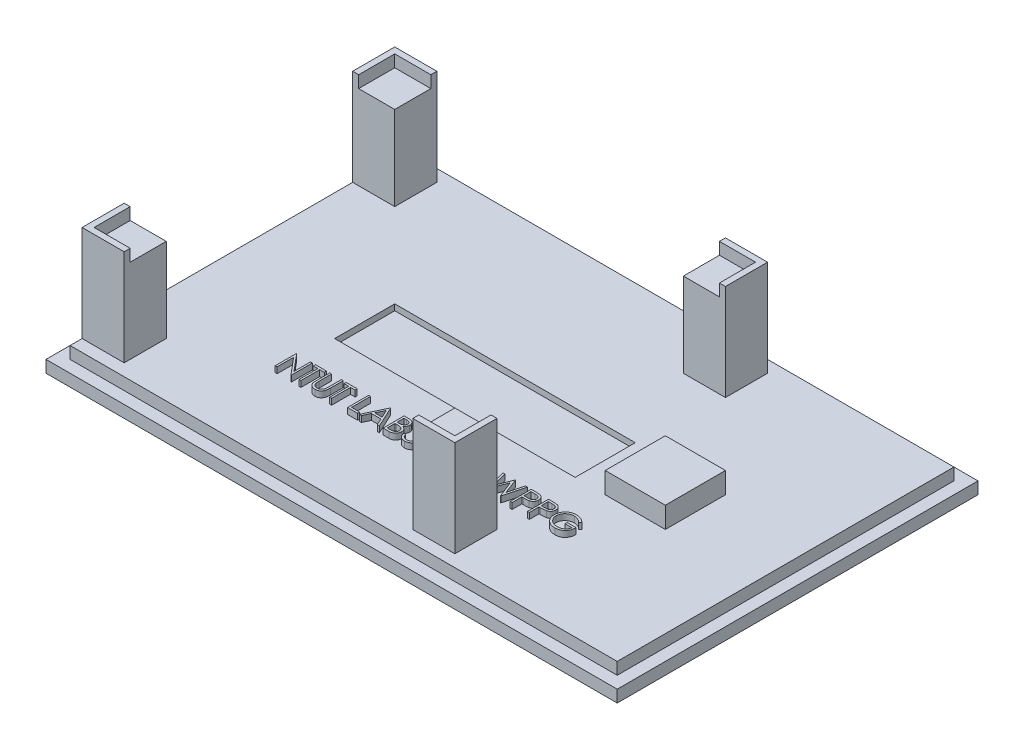
from build123d import *

# Parameters (mm, degrees)
SKETCH_1_W          = 95
SKETCH_1_H          = 60
EXTRUDE_1_DEPTH     = 2
SKETCH_2_W          = 91
SKETCH_2_H          = 56
EXTRUDE_2_DEPTH     = 2
SKETCH_5_W          = 10
SKETCH_5_H          = 10
EXTRUDE_6_DEPTH     = 3.5
SKETCH_15_W         = 7
SKETCH_15_H         = 7
EXTRUDE_7_DEPTH     = 16
SKETCH_27_W         = 6
SKETCH_27_H         = 6
CUT_EXTRUDE_1_DEPTH = 2
SKETCH_28_W         = 40
SKETCH_28_H         = 10
CUT_EXTRUDE_2_DEPTH = 1
EXTRUDE_8_DEPTH     = 1


with BuildPart() as part:
    # 草圖1 → 填料-伸長1 (new body)
    with BuildSketch(Plane(origin=(0, 0, 0), x_dir=(1, 0, 0), z_dir=(0, 1, 0))):
        with Locations((47.5, 30)):
            Rectangle(SKETCH_1_W, SKETCH_1_H)
    extrude(amount=EXTRUDE_1_DEPTH)

    # 草圖2 → 填料-伸長2 (add)
    with BuildSketch(Plane(origin=(0, 2, 0), x_dir=(1, 0, 0), z_dir=(0, 1, 0))):
        with Locations((47.5, 30)):
            Rectangle(SKETCH_2_W, SKETCH_2_H)
    extrude(amount=EXTRUDE_2_DEPTH)

    # 草圖5 → 填料-伸長6 (add)
    with BuildSketch(Plane(origin=(0, 4, 0), x_dir=(1, 0, 0), z_dir=(0, 1, 0))):
        with Locations((73, 30)):
            Rectangle(SKETCH_5_W, SKETCH_5_H)
    extrude(amount=EXTRUDE_6_DEPTH)

    # 草圖15 → 填料-伸長7 (add)
    with BuildSketch(Plane(origin=(0, 4, 0), x_dir=(1, 0, 0), z_dir=(0, 1, 0))):
        with Locations((5.5, 7.5)):
            Rectangle(SKETCH_15_W, SKETCH_15_H)
        with Locations((5.5, 52.5)):
            Rectangle(SKETCH_15_W, SKETCH_15_H)
        with Locations((60.5, 52.5)):
            Rectangle(SKETCH_15_W, SKETCH_15_H)
        with Locations((60.5, 7.5)):
            Rectangle(SKETCH_15_W, SKETCH_15_H)
    extrude(amount=EXTRUDE_7_DEPTH)

    # 草圖27 → 除料-伸長1 (cut)
    with BuildSketch(Plane(origin=(0, 20, 0), x_dir=(1, 0, 0), z_dir=(0, 1, 0))):
        with Locations((6, 52)):
            Rectangle(SKETCH_27_W, SKETCH_27_H)
        with Locations((60, 52)):
            Rectangle(SKETCH_27_W, SKETCH_27_H)
        with Locations((60, 8)):
            Rectangle(SKETCH_27_W, SKETCH_27_H)
        with Locations((6, 8)):
            Rectangle(SKETCH_27_W, SKETCH_27_H)
    extrude(amount=-CUT_EXTRUDE_1_DEPTH, mode=Mode.SUBTRACT)

    # 草圖28 → 除料-伸長2 (cut)
    with BuildSketch(Plane(origin=(0, 4, 0), x_dir=(1, 0, 0), z_dir=(0, 1, 0))):
        with Locations((43, 30)):
            Rectangle(SKETCH_28_W, SKETCH_28_H)
    extrude(amount=-CUT_EXTRUDE_2_DEPTH, mode=Mode.SUBTRACT)

    # 草圖29 → 填料-伸長8 (add)
    with BuildSketch(Plane(origin=(0, 4, 0), x_dir=(1, 0, 0), z_dir=(0, 1, 0))):
        Polygon((22.976581765, 15.14183964), (22.976581765, 18.64183964), (23.042487214, 18.64183964), (25.354786894, 15.887132108), (25.354786894, 18.64183964), (25.668889458, 18.64183964), (25.668889458, 15.14183964), (25.597375035, 15.14183964), (23.290684329, 17.890237076), (23.290684329, 15.14183964), align=None)
        Polygon((26.162479201, 18.282865281), (26.162479201, 18.64183964), (28.002222791, 18.64183964), (28.002222791, 18.282865281), (27.239402278, 18.282865281), (27.239402278, 15.14183964), (26.925299714, 15.14183964), (26.925299714, 18.282865281), align=None)
        with BuildLine():
            Line((28.540684329, 18.64183964), (28.854786894, 18.64183964))
            Line((28.854786894, 18.64183964), (28.854786894, 16.544784352))
            add(Edge.make_bspline(
                [(28.854786894, 16.544784352), (28.85474015, 16.515103616), (28.854651445, 16.458779305), (28.855243959, 16.378611005), (28.856903327, 16.307338546), (28.857949487, 16.244687198), (28.86027682, 16.190944451), (28.862174867, 16.14581914), (28.864615424, 16.109524937), (28.867548541, 16.088344011), (28.868809329, 16.07923948)],
                knots=[0, 0, 0, 0, 1.528628734, 2.90083645, 4.128790002, 5.200304208, 6.127813768, 6.898992206, 7.526736466, 8, 8, 8, 8], degree=3))
            add(Edge.make_bspline(
                [(28.868809329, 16.07923948), (28.873986788, 16.046392717), (28.884049975, 15.982549988), (28.909696352, 15.891641706), (28.945513853, 15.809710248), (28.987956896, 15.734198956), (29.043889507, 15.667209596), (29.110893043, 15.605497944), (29.192070811, 15.551526139), (29.282331417, 15.502175327), (29.379616654, 15.462510245), (29.479027921, 15.43251688), (29.5790709, 15.414237981), (29.646047065, 15.412121442), (29.679306124, 15.41107041)],
                knots=[0, 0, 0, 0, 1.035780045, 2.013197591, 2.933192213, 3.817615948, 4.702609284, 5.640816605, 6.646850145, 7.73207398, 8.84249596, 9.914020372, 10.964143139, 12, 12, 12, 12], degree=3))
            add(Edge.make_bspline(
                [(29.679306124, 15.41107041), (29.707859865, 15.41214426), (29.764802427, 15.414285758), (29.849408857, 15.427547189), (29.931808966, 15.451447755), (30.012409646, 15.482287513), (30.08796063, 15.523035104), (30.158504072, 15.570105944), (30.221468007, 15.62531682), (30.278926004, 15.686417164), (30.32896094, 15.755356964), (30.372332082, 15.830635102), (30.407858011, 15.913384449), (30.425401536, 15.971538872), (30.434414297, 16.001414961)],
                knots=[0, 0, 0, 0, 0.994687771, 1.983630487, 2.973142513, 3.978332533, 4.983357753, 5.956394766, 6.925816176, 7.893390482, 8.871859704, 9.88551698, 10.913711441, 12, 12, 12, 12], degree=3))
            add(Edge.make_bspline(
                [(30.434414297, 16.001414961), (30.437414423, 16.013763535), (30.444099911, 16.041281135), (30.450346956, 16.087802426), (30.456853481, 16.14269179), (30.461368051, 16.206343603), (30.465769272, 16.278544575), (30.468402345, 16.359670833), (30.469619377, 16.449427794), (30.469982058, 16.512064955), (30.470171509, 16.544784352)],
                knots=[0, 0, 0, 0, 0.558680831, 1.244966039, 2.062412453, 2.990489873, 4.051219941, 5.244515665, 6.560634259, 8, 8, 8, 8], degree=3))
            Line((30.470171509, 16.544784352), (30.470171509, 18.64183964))
            Line((30.470171509, 18.64183964), (30.784274073, 18.64183964))
            Line((30.784274073, 18.64183964), (30.784274073, 16.527957429))
            add(Edge.make_bspline(
                [(30.784274073, 16.527957429), (30.784019953, 16.48985905), (30.783524021, 16.415507747), (30.779223445, 16.306556388), (30.772366445, 16.203203407), (30.762678357, 16.10543491), (30.749841354, 16.013600751), (30.735566133, 15.926895983), (30.7173866, 15.84594299), (30.696153199, 15.770110572), (30.671879651, 15.697925059), (30.640438503, 15.629416444), (30.605014003, 15.562502045), (30.56299935, 15.498193936), (30.515787967, 15.436207383), (30.462336286, 15.376918308), (30.404412126, 15.319379261), (30.341052566, 15.265066195), (30.273302041, 15.215257518), (30.201362083, 15.171459747), (30.125785313, 15.13443613), (30.046768187, 15.103960205), (29.964276984, 15.081045606), (29.878309625, 15.06397045), (29.788670431, 15.054268153), (29.727705775, 15.052826223), (29.696834169, 15.052096051)],
                knots=[0, 0, 0, 0, 1.316592851, 2.569410997, 3.76748051, 4.895814652, 5.963796859, 6.97159953, 7.931736103, 8.829262218, 9.692595152, 10.560224239, 11.431080259, 12.30701507, 13.211635791, 14.121146779, 15.063487852, 16.031507147, 17.00238618, 17.966455255, 18.938106653, 19.907068911, 20.888905087, 21.893141452, 22.933117798, 24, 24, 24, 24], degree=3))
            add(Edge.make_bspline(
                [(29.696834169, 15.052096051), (29.663165067, 15.052880816), (29.597106408, 15.054420523), (29.49976834, 15.063243273), (29.406454144, 15.079861667), (29.316178267, 15.101021611), (29.23016977, 15.130205348), (29.147276326, 15.164303473), (29.068917644, 15.206180733), (28.993822516, 15.252774126), (28.92399776, 15.305198764), (28.859900357, 15.362338938), (28.801424486, 15.423279316), (28.74955579, 15.488679681), (28.703434905, 15.558031388), (28.663704692, 15.631530628), (28.629591448, 15.709148944), (28.611984881, 15.763102145), (28.603084169, 15.790377301)],
                knots=[0, 0, 0, 0, 1.13879206, 2.234305948, 3.301075583, 4.341971843, 5.366689343, 6.369221514, 7.369726634, 8.367512178, 9.355451585, 10.318319045, 11.268648973, 12.207971039, 13.137398894, 14.081662264, 15.030215811, 16, 16, 16, 16], degree=3))
            add(Edge.make_bspline(
                [(28.603084169, 15.790377301), (28.597907011, 15.809009875), (28.58667764, 15.849424344), (28.574652342, 15.916310833), (28.56454326, 15.99332575), (28.555037702, 16.080474369), (28.549428744, 16.177824235), (28.544511306, 16.285333151), (28.540649687, 16.403131113), (28.540672459, 16.485185628), (28.540684329, 16.527957429)],
                knots=[0, 0, 0, 0, 0.625038921, 1.35572334, 2.194682327, 3.136881307, 4.189498639, 5.346923369, 6.617055217, 8, 8, 8, 8], degree=3))
            Line((28.540684329, 16.527957429), (28.540684329, 18.64183964))
        make_face()
        Polygon((31.277863817, 18.282865281), (31.277863817, 18.64183964), (33.117607406, 18.64183964), (33.117607406, 18.282865281), (32.354786894, 18.282865281), (32.354786894, 15.14183964), (32.040684329, 15.14183964), (32.040684329, 18.282865281), align=None)
        Polygon((35.002222791, 18.64183964), (35.316325355, 18.64183964), (35.316325355, 15.500813999), (36.662479201, 15.500813999), (36.662479201, 15.14183964), (35.002222791, 15.14183964), align=None)
        Polygon((38.681709971, 18.64183964), (40.297094586, 15.14183964), (39.955648272, 15.14183964), (39.438220387, 16.263634512), (37.851581765, 16.263634512), (37.319430323, 15.14183964), (36.976581765, 15.14183964), (38.636838176, 18.64183964), align=None)
        Polygon((38.655768464, 17.959648134), (38.021954362, 16.622608871), (39.272755644, 16.622608871), align=None, mode=Mode.SUBTRACT)
        with BuildLine():
            Line((40.925299714, 18.64183964), (41.608192342, 18.64183964))
            add(Edge.make_bspline(
                [(41.608192342, 18.64183964), (41.64162082, 18.64166389), (41.706413531, 18.641323242), (41.800632973, 18.636040111), (41.888881783, 18.628836441), (41.971185556, 18.617406348), (42.047506258, 18.603614571), (42.118073895, 18.586912755), (42.182664068, 18.566886141), (42.259776804, 18.53503986), (42.347697465, 18.487716692), (42.442895858, 18.417788127), (42.524300097, 18.332255664), (42.594486414, 18.235773008), (42.650287534, 18.129637236), (42.690656831, 18.016378048), (42.716214706, 17.897456306), (42.718843141, 17.815813128), (42.720171509, 17.77455198)],
                knots=[0, 0, 0, 0, 1.001505555, 1.941167018, 2.826882275, 3.653841531, 4.429895133, 5.150066043, 5.825578002, 6.45369114, 7.647487171, 8.808567382, 9.977351308, 11.170798116, 12.373658725, 13.556498008, 14.765093433, 16, 16, 16, 16], degree=3))
            add(Edge.make_bspline(
                [(42.720171509, 17.77455198), (42.719078291, 17.735899424), (42.716930013, 17.659943507), (42.696387254, 17.548849398), (42.664226585, 17.443098179), (42.619521336, 17.343075794), (42.56141934, 17.251042181), (42.492561021, 17.166254915), (42.409484219, 17.092303858), (42.347240979, 17.050960955), (42.315624233, 17.029960634)],
                knots=[0, 0, 0, 0, 1.044552857, 2.05264487, 3.044412934, 4.028983338, 5.005914585, 5.980388656, 6.974128949, 8, 8, 8, 8], degree=3))
            add(Edge.make_bspline(
                [(42.315624233, 17.029960634), (42.355384661, 17.014695635), (42.431456208, 16.985489911), (42.536142221, 16.933854447), (42.626337066, 16.877692336), (42.702734212, 16.816360486), (42.768071867, 16.750251675), (42.825124808, 16.678396561), (42.873806182, 16.599857803), (42.915519106, 16.515454268), (42.948067862, 16.426047799), (42.972443766, 16.332477023), (42.986411215, 16.235077468), (42.988398857, 16.168792089), (42.989402278, 16.135329224)],
                knots=[0, 0, 0, 0, 1.27268992, 2.434971085, 3.483601985, 4.442670788, 5.356604649, 6.2567628, 7.179492994, 8.113709626, 9.066344395, 10.018646069, 10.999752585, 12, 12, 12, 12], degree=3))
            add(Edge.make_bspline(
                [(42.989402278, 16.135329224), (42.988425432, 16.101162352), (42.98650346, 16.033938073), (42.972323488, 15.935182939), (42.948314381, 15.840807992), (42.915243235, 15.75020281), (42.872080921, 15.663542675), (42.819552956, 15.580729411), (42.756921393, 15.502595081), (42.686858524, 15.428271457), (42.607596378, 15.36144367), (42.522080623, 15.301927963), (42.429234303, 15.252981901), (42.330582309, 15.21186588), (42.225017993, 15.180458681), (42.113015386, 15.158486107), (41.994671084, 15.14368107), (41.913461333, 15.142463866), (41.871814137, 15.14183964)],
                knots=[0, 0, 0, 0, 0.978564426, 1.925352924, 2.850884081, 3.763762016, 4.682927383, 5.618979971, 6.567305752, 7.547517671, 8.540179244, 9.531824382, 10.526200242, 11.540722885, 12.589160233, 13.674978461, 14.80764778, 16, 16, 16, 16], degree=3))
            Line((41.871814137, 15.14183964), (40.925299714, 15.14183964))
            Line((40.925299714, 15.14183964), (40.925299714, 18.64183964))
        make_face()
        with BuildLine():
            Line((41.239402278, 18.282865281), (41.239402278, 17.16107041))
            Line((41.239402278, 17.16107041), (41.450439938, 17.16107041))
            add(Edge.make_bspline(
                [(41.450439938, 17.16107041), (41.481288734, 17.161470333), (41.540894893, 17.162243065), (41.62721479, 17.164456582), (41.707339808, 17.170654626), (41.781131641, 17.176850888), (41.848474085, 17.186925476), (41.909217946, 17.198917598), (41.964316543, 17.211600504), (42.027856089, 17.23316999), (42.099929037, 17.265047666), (42.176762141, 17.314519502), (42.244496611, 17.373443855), (42.301693799, 17.441434817), (42.348505269, 17.516301003), (42.381018984, 17.596847883), (42.403066269, 17.681068015), (42.4050578, 17.738886268), (42.406068945, 17.768241884)],
                knots=[0, 0, 0, 0, 1.156816544, 2.235205308, 3.236616184, 4.169592532, 5.011045266, 5.787822928, 6.49130361, 7.128639758, 8.301311294, 9.436451833, 10.541879658, 11.654887649, 12.756523258, 13.837046038, 14.901820046, 16, 16, 16, 16], degree=3))
            add(Edge.make_bspline(
                [(42.406068945, 17.768241884), (42.405542765, 17.787667655), (42.404510605, 17.825773428), (42.396057302, 17.881322782), (42.381689728, 17.933566534), (42.363235435, 17.983220645), (42.337446746, 18.028732495), (42.307083282, 18.071675691), (42.270397592, 18.110587809), (42.22864028, 18.146957307), (42.180631657, 18.179201835), (42.126400365, 18.207442598), (42.065212688, 18.230183375), (41.998099833, 18.250099527), (41.924028745, 18.264087821), (41.843854192, 18.275741209), (41.756919473, 18.281673951), (41.69677437, 18.282459314), (41.665684329, 18.282865281)],
                knots=[0, 0, 0, 0, 0.91205012, 1.789085906, 2.630437955, 3.453916878, 4.269457761, 5.079663411, 5.91843418, 6.774407191, 7.675494373, 8.627863946, 9.638891023, 10.736472738, 11.911756761, 13.175263542, 14.539845004, 16, 16, 16, 16], degree=3))
            Line((41.665684329, 18.282865281), (41.239402278, 18.282865281))
        make_face(mode=Mode.SUBTRACT)
        with BuildLine():
            Line((41.239402278, 16.802096051), (41.239402278, 15.500813999))
            Line((41.239402278, 15.500813999), (41.686717983, 15.500813999))
            add(Edge.make_bspline(
                [(41.686717983, 15.500813999), (41.718736909, 15.501197747), (41.780449168, 15.501937369), (41.869550398, 15.504351924), (41.952133502, 15.5098442), (42.027821637, 15.518490049), (42.09743209, 15.527868498), (42.160129793, 15.540479779), (42.216422987, 15.55492874), (42.281697294, 15.577262912), (42.355200803, 15.611959383), (42.434411659, 15.664273609), (42.504837877, 15.726596917), (42.564643136, 15.798727831), (42.613656125, 15.877159158), (42.64931158, 15.960304508), (42.671302437, 16.046790036), (42.673964606, 16.105756748), (42.675299714, 16.135329224)],
                knots=[0, 0, 0, 0, 1.160039823, 2.235823828, 3.228722157, 4.157150951, 4.99529583, 5.772374946, 6.472645482, 7.099169577, 8.269452708, 9.405989375, 10.527446681, 11.663510218, 12.788923519, 13.866172445, 14.929861265, 16, 16, 16, 16], degree=3))
            add(Edge.make_bspline(
                [(42.675299714, 16.135329224), (42.67502361, 16.153822564), (42.674475855, 16.190510946), (42.66621524, 16.244426765), (42.65420137, 16.296652639), (42.638669936, 16.347330379), (42.616050469, 16.395543755), (42.589643924, 16.442246315), (42.558682522, 16.487499794), (42.510438356, 16.544712048), (42.440266372, 16.610629061), (42.340559596, 16.675166563), (42.227187299, 16.72721437), (42.144959806, 16.749313846), (42.102483208, 16.760729865)],
                knots=[0, 0, 0, 0, 0.723448775, 1.435228256, 2.130040452, 2.821711965, 3.505591119, 4.210454504, 4.921174351, 5.648778258, 7.137944449, 8.670945889, 10.280296675, 12, 12, 12, 12], degree=3))
            add(Edge.make_bspline(
                [(42.102483208, 16.760729865), (42.085454112, 16.764184949), (42.048531519, 16.771676283), (41.988323939, 16.779583987), (41.91958807, 16.786629047), (41.842165193, 16.791840204), (41.755957352, 16.797226748), (41.660780433, 16.799321569), (41.557023118, 16.801820829), (41.485030746, 16.802001963), (41.447635451, 16.802096051)],
                knots=[0, 0, 0, 0, 0.634451884, 1.375622551, 2.216452059, 3.157844607, 4.20941857, 5.370758133, 6.634282058, 8, 8, 8, 8], degree=3))
            Line((41.447635451, 16.802096051), (41.239402278, 16.802096051))
        make_face(mode=Mode.SUBTRACT)
        with BuildLine():
            Line((43.841966381, 17.834147333), (43.527863817, 17.834147333))
            add(Edge.make_bspline(
                [(43.527863817, 17.834147333), (43.536373367, 17.869379817), (43.553008843, 17.938256441), (43.587706416, 18.036663702), (43.625505672, 18.129787223), (43.670894776, 18.215883297), (43.72040353, 18.2966822), (43.777126252, 18.370351324), (43.838445974, 18.43876429), (43.906270924, 18.499477527), (43.977399585, 18.554455256), (44.052834205, 18.601330314), (44.131057099, 18.641654467), (44.212610232, 18.674874699), (44.297736403, 18.699900222), (44.385666027, 18.718057028), (44.476629527, 18.729848142), (44.538377117, 18.730998905), (44.569730804, 18.73158323)],
                knots=[0, 0, 0, 0, 1.162005537, 2.271625781, 3.343758855, 4.383309926, 5.390229558, 6.379919256, 7.361854164, 8.333198761, 9.295911338, 10.242430842, 11.177959212, 12.116337295, 13.062827104, 14.020064771, 14.994644689, 16, 16, 16, 16], degree=3))
            add(Edge.make_bspline(
                [(44.569730804, 18.73158323), (44.615413546, 18.730204), (44.705782557, 18.727475624), (44.838545604, 18.702561188), (44.966572423, 18.663136056), (45.088461671, 18.608662328), (45.201680103, 18.541475015), (45.30241629, 18.461510278), (45.389304801, 18.370310977), (45.462199179, 18.269578413), (45.519274178, 18.161922903), (45.561360551, 18.051122746), (45.586982232, 17.937440775), (45.590302789, 17.860683495), (45.591966381, 17.822228262)],
                knots=[0, 0, 0, 0, 1.083050992, 2.142477498, 3.193116406, 4.255571735, 5.30263384, 6.308962982, 7.297363603, 8.282367274, 9.249857812, 10.179914175, 11.08814088, 12, 12, 12, 12], degree=3))
            add(Edge.make_bspline(
                [(45.591966381, 17.822228262), (45.59080279, 17.785221467), (45.588525823, 17.712804913), (45.569192117, 17.607083416), (45.536655854, 17.507441816), (45.491586092, 17.413460653), (45.433244541, 17.325735814), (45.362571844, 17.244069923), (45.279069183, 17.168100765), (45.215790245, 17.124581292), (45.183212374, 17.102176179)],
                knots=[0, 0, 0, 0, 1.024540389, 2.004866551, 2.965041327, 3.920577974, 4.882998113, 5.874504559, 6.905732034, 8, 8, 8, 8], degree=3))
            add(Edge.make_bspline(
                [(45.183212374, 17.102176179), (45.220444129, 17.084198007), (45.294211003, 17.04857805), (45.394761533, 16.978722292), (45.486039408, 16.898065945), (45.536943127, 16.835123292), (45.562519265, 16.803498294)],
                knots=[0, 0, 0, 0, 1.015518401, 2.012035669, 3.001164323, 4, 4, 4, 4], degree=3))
            add(Edge.make_bspline(
                [(45.562519265, 16.803498294), (45.579360608, 16.780440543), (45.612767504, 16.734702626), (45.654003038, 16.6611662), (45.691412152, 16.586814711), (45.720562371, 16.509655305), (45.743136238, 16.430582291), (45.75927227, 16.349459895), (45.769296411, 16.266221873), (45.770731963, 16.209909392), (45.77145356, 16.181603262)],
                knots=[0, 0, 0, 0, 1.025084078, 2.033381695, 3.024893161, 4.013698104, 4.991890475, 5.976764909, 6.982997093, 8, 8, 8, 8], degree=3))
            add(Edge.make_bspline(
                [(45.77145356, 16.181603262), (45.769659047, 16.132593541), (45.766078465, 16.034804739), (45.73407439, 15.890330018), (45.68446115, 15.749104515), (45.614004214, 15.614029676), (45.528136705, 15.487649295), (45.425979381, 15.374572986), (45.308692972, 15.277374382), (45.177887323, 15.196164154), (45.036170195, 15.131246231), (44.884594603, 15.086188789), (44.725344549, 15.056842789), (44.616137251, 15.05369592), (44.560616221, 15.052096051)],
                knots=[0, 0, 0, 0, 0.955779014, 1.907060117, 2.875433937, 3.871313158, 4.872415639, 5.851225146, 6.836215519, 7.83643374, 8.849228613, 9.86973379, 10.916971861, 12, 12, 12, 12], degree=3))
            add(Edge.make_bspline(
                [(44.560616221, 15.052096051), (44.52319692, 15.052964264), (44.449568215, 15.054672618), (44.341324717, 15.066351219), (44.238003017, 15.087681225), (44.13946342, 15.11638453), (44.045618383, 15.152776272), (43.956754278, 15.19809497), (43.872324384, 15.251406472), (43.793125433, 15.31334006), (43.719166866, 15.3826214), (43.652414141, 15.46048041), (43.591754348, 15.545477813), (43.53881171, 15.63860087), (43.491174757, 15.738646127), (43.4519938, 15.846894625), (43.417508232, 15.962378647), (43.401474768, 16.042856388), (43.393248432, 16.084147333)],
                knots=[0, 0, 0, 0, 1.048658725, 2.063410685, 3.046034179, 4.001477787, 4.936774919, 5.862367409, 6.792675028, 7.730719943, 8.675894397, 9.627829632, 10.600096036, 11.597688215, 12.626045268, 13.701542398, 14.82072376, 16, 16, 16, 16], degree=3))
            Line((43.393248432, 16.084147333), (43.707350996, 16.084147333))
            add(Edge.make_bspline(
                [(43.707350996, 16.084147333), (43.715534288, 16.057198319), (43.7314515, 16.004780148), (43.758545798, 15.929339842), (43.78941407, 15.860181789), (43.822528629, 15.796798667), (43.857307075, 15.738566264), (43.896222, 15.687024395), (43.936391145, 15.639909193), (43.966670499, 15.613364581), (43.981489618, 15.600373294)],
                knots=[0, 0, 0, 0, 1.198163088, 2.33053128, 3.407730985, 4.417276592, 5.372219308, 6.28897303, 7.162600585, 8, 8, 8, 8], degree=3))
            add(Edge.make_bspline(
                [(43.981489618, 15.600373294), (44.001086194, 15.58526496), (44.040218857, 15.555094929), (44.103987088, 15.5165933), (44.171051975, 15.483232275), (44.242866649, 15.457748579), (44.317881419, 15.436170918), (44.397308784, 15.422050399), (44.480448002, 15.412362228), (44.537215765, 15.411507296), (44.566225195, 15.41107041)],
                knots=[0, 0, 0, 0, 0.946170439, 1.889420265, 2.845303464, 3.807233317, 4.801018734, 5.828864929, 6.890507805, 8, 8, 8, 8], degree=3))
            add(Edge.make_bspline(
                [(44.566225195, 15.41107041), (44.598978698, 15.411686315), (44.663025344, 15.412890664), (44.756480204, 15.423966371), (44.845387651, 15.440096785), (44.928760577, 15.465009768), (45.007691084, 15.495790619), (45.081072734, 15.534439024), (45.14986884, 15.579783746), (45.213198246, 15.631322905), (45.270143753, 15.6877444), (45.320283266, 15.746757471), (45.362907928, 15.8081133), (45.397291506, 15.872151421), (45.424442056, 15.93860665), (45.442925257, 16.00766548), (45.455776772, 16.078762746), (45.456823384, 16.127091715), (45.457350996, 16.151455025)],
                knots=[0, 0, 0, 0, 1.217147791, 2.380027433, 3.494444702, 4.572153297, 5.609568379, 6.639424714, 7.649109417, 8.668170816, 9.669597737, 10.625200337, 11.543417969, 12.441394052, 13.322311151, 14.205496177, 15.095365482, 16, 16, 16, 16], degree=3))
            add(Edge.make_bspline(
                [(45.457350996, 16.151455025), (45.455820695, 16.184066364), (45.452767706, 16.249126772), (45.429459127, 16.344844346), (45.391120262, 16.437067759), (45.337447751, 16.524223549), (45.272112023, 16.60499945), (45.195747116, 16.677070933), (45.107718887, 16.736541024), (45.026699018, 16.77762968), (44.954933862, 16.805666756), (44.893518477, 16.82434172), (44.824761874, 16.840155376), (44.749495525, 16.854867647), (44.667152309, 16.867388995), (44.577821871, 16.877830811), (44.481486109, 16.886185852), (44.414794943, 16.889916947), (44.380427919, 16.89183964)],
                knots=[0, 0, 0, 0, 1.07054697, 2.135767047, 3.216561865, 4.33974944, 5.486079747, 6.621378074, 7.775625952, 8.963672916, 9.598146892, 10.304877434, 11.070270905, 11.915000392, 12.823868403, 13.805723172, 14.86925407, 16, 16, 16, 16], degree=3))
            Line((44.380427919, 16.89183964), (44.380427919, 17.250813999))
            add(Edge.make_bspline(
                [(44.380427919, 17.250813999), (44.423729085, 17.251548803), (44.508545432, 17.252988103), (44.632439736, 17.270396113), (44.750913048, 17.294476742), (44.86133979, 17.331361934), (44.961988504, 17.374202231), (45.049308106, 17.42405444), (45.122075253, 17.479469189), (45.179936325, 17.541301799), (45.223465553, 17.607616846), (45.255292351, 17.676733504), (45.274092677, 17.749257565), (45.276602344, 17.798752233), (45.277863817, 17.823630506)],
                knots=[0, 0, 0, 0, 1.321986639, 2.589447074, 3.816329219, 5.01088745, 6.139805852, 7.153945165, 8.075214402, 8.924034688, 9.728124013, 10.488707548, 11.240355623, 12, 12, 12, 12], degree=3))
            add(Edge.make_bspline(
                [(45.277863817, 17.823630506), (45.277449406, 17.841908251), (45.276624955, 17.878270958), (45.266227677, 17.931396027), (45.250603636, 17.982896973), (45.229123907, 18.032554783), (45.200373708, 18.080025057), (45.165967721, 18.125712506), (45.124999621, 18.169356285), (45.078054174, 18.210036604), (45.027642369, 18.248805841), (44.972392594, 18.281719478), (44.913970719, 18.309864541), (44.852312065, 18.333074043), (44.787216534, 18.350533331), (44.718989977, 18.363069172), (44.647502293, 18.370906827), (44.598730561, 18.372035243), (44.573937535, 18.372608871)],
                knots=[0, 0, 0, 0, 0.884392785, 1.759457502, 2.611959086, 3.489218968, 4.37281399, 5.2945488, 6.255912374, 7.266815255, 8.301784654, 9.332968512, 10.37626691, 11.440494194, 12.520033166, 13.637162961, 14.798855837, 16, 16, 16, 16], degree=3))
            add(Edge.make_bspline(
                [(44.573937535, 18.372608871), (44.534085867, 18.371217509), (44.45624629, 18.368499856), (44.344031373, 18.344696842), (44.239712039, 18.306718759), (44.159973373, 18.261385739), (44.101090799, 18.216635305), (44.05901386, 18.177552919), (44.01769335, 18.134120095), (43.979847673, 18.08366172), (43.941573696, 18.02959493), (43.906729135, 17.969171248), (43.872869443, 17.903966854), (43.852466893, 17.857871219), (43.841966381, 17.834147333)],
                knots=[0, 0, 0, 0, 1.472543308, 2.876219568, 4.221790263, 5.565193594, 6.249813518, 6.953379497, 7.687249741, 8.463570142, 9.283606569, 10.136032583, 11.040678096, 12, 12, 12, 12], degree=3))
        make_face()
        with BuildLine():
            Line((46.534274073, 17.564916563), (46.220171509, 17.564916563))
            add(Edge.make_bspline(
                [(46.220171509, 17.564916563), (46.222218662, 17.606587451), (46.226239216, 17.688427966), (46.245067505, 17.807751872), (46.272008382, 17.921806671), (46.310099836, 18.029676585), (46.357406114, 18.132315392), (46.414136142, 18.229315408), (46.481329992, 18.320306597), (46.557536726, 18.40444544), (46.640305365, 18.481633011), (46.729611305, 18.548288253), (46.823456332, 18.604605925), (46.921555731, 18.651687167), (47.025016295, 18.687027013), (47.132899152, 18.713248652), (47.245678289, 18.729024998), (47.322518311, 18.730720783), (47.361597791, 18.73158323)],
                knots=[0, 0, 0, 0, 1.10065271, 2.161652631, 3.183658789, 4.190468796, 5.17591951, 6.163126047, 7.15150782, 8.156236427, 9.156009102, 10.134482811, 11.092018607, 12.041330605, 13.001268258, 13.972401359, 14.968799086, 16, 16, 16, 16], degree=3))
            add(Edge.make_bspline(
                [(47.361597791, 18.73158323), (47.399975865, 18.730684774), (47.47538741, 18.728919339), (47.585449424, 18.71375831), (47.690226719, 18.690012718), (47.789514485, 18.656697302), (47.88252055, 18.611912874), (47.969943594, 18.558115336), (48.052824405, 18.495895504), (48.127431189, 18.422641691), (48.195939268, 18.344439306), (48.255041523, 18.260951403), (48.305654687, 18.174722117), (48.347842366, 18.085093915), (48.378898505, 17.991222887), (48.402476713, 17.894475684), (48.415804127, 17.793850873), (48.417849551, 17.725744318), (48.418889458, 17.691118487)],
                knots=[0, 0, 0, 0, 1.111607364, 2.184268762, 3.212621178, 4.221274766, 5.211760367, 6.196651075, 7.1921475, 8.207485113, 9.220403448, 10.201281604, 11.166441695, 12.114753415, 13.065576456, 14.026450734, 14.996634279, 16, 16, 16, 16], degree=3))
            add(Edge.make_bspline(
                [(48.418889458, 17.691118487), (48.417196195, 17.642370652), (48.413839383, 17.545730438), (48.385125007, 17.403715576), (48.340278496, 17.266122156), (48.286281139, 17.155384854), (48.231808695, 17.066151361), (48.182721187, 16.992682656), (48.125256376, 16.913577187), (48.058577878, 16.82909985), (47.984065006, 16.738588945), (47.901042843, 16.642099149), (47.808919361, 16.54062738), (47.74426086, 16.471321778), (47.710756445, 16.435409352)],
                knots=[0, 0, 0, 0, 1.184426356, 2.348067706, 3.509069118, 4.696110526, 5.333549288, 6.050745305, 6.844228056, 7.710549037, 8.667450064, 9.695053472, 10.805634456, 12, 12, 12, 12], degree=3))
            Line((47.710756445, 16.435409352), (46.835055323, 15.500813999))
            Line((46.835055323, 15.500813999), (48.463761253, 15.500813999))
            Line((48.463761253, 15.500813999), (48.463761253, 15.14183964))
            Line((48.463761253, 15.14183964), (46.085556124, 15.14183964))
            Line((46.085556124, 15.14183964), (47.442927919, 16.590357269))
            add(Edge.make_bspline(
                [(47.442927919, 16.590357269), (47.475975806, 16.624855575), (47.539454033, 16.691119762), (47.62923661, 16.787862722), (47.709875598, 16.877612263), (47.781892991, 16.960198811), (47.843726496, 17.036830379), (47.898598728, 17.105025082), (47.942564319, 17.167779533), (47.990279715, 17.240520147), (48.036493696, 17.329332464), (48.076206052, 17.437866153), (48.100420901, 17.549593406), (48.103325736, 17.625095443), (48.104786894, 17.663073615)],
                knots=[0, 0, 0, 0, 1.329631726, 2.553950428, 3.673215718, 4.687767853, 5.603093632, 6.413772471, 7.123043292, 7.734684054, 8.834405432, 9.900288307, 10.943827018, 12, 12, 12, 12], degree=3))
            add(Edge.make_bspline(
                [(48.104786894, 17.663073615), (48.104151151, 17.686955013), (48.102898225, 17.734020664), (48.091840528, 17.803026423), (48.075130022, 17.869591236), (48.051184764, 17.933919855), (48.019578024, 17.995365508), (47.981104644, 18.054002988), (47.93671458, 18.110691953), (47.885363311, 18.163845251), (47.828951791, 18.212526456), (47.769357542, 18.255650542), (47.706307437, 18.291689653), (47.640067315, 18.32123315), (47.570821846, 18.344408531), (47.498437101, 18.36046711), (47.423113084, 18.370549594), (47.371679589, 18.371913766), (47.34547199, 18.372608871)],
                knots=[0, 0, 0, 0, 0.991446411, 1.95395049, 2.89581595, 3.838931463, 4.798493298, 5.75982156, 6.748411868, 7.785213223, 8.824556874, 9.840280684, 10.836137867, 11.835679398, 12.848801643, 13.863922112, 14.911575587, 16, 16, 16, 16], degree=3))
            add(Edge.make_bspline(
                [(47.34547199, 18.372608871), (47.318101157, 18.371893839), (47.264349361, 18.370489634), (47.185430328, 18.36066697), (47.11014455, 18.343721129), (47.038302647, 18.320544455), (46.969783062, 18.291085906), (46.904919017, 18.254394161), (46.843856128, 18.210610668), (46.786479605, 18.160970112), (46.733615626, 18.105702511), (46.68716875, 18.044092548), (46.646584736, 17.977265132), (46.611175502, 17.905400582), (46.582419812, 17.827846802), (46.560446662, 17.744879097), (46.543059815, 17.656857715), (46.537251294, 17.59607263), (46.534274073, 17.564916563)],
                knots=[0, 0, 0, 0, 1.031018746, 2.02475058, 2.990194455, 3.934040569, 4.864654155, 5.795059489, 6.735614925, 7.690564532, 8.649604399, 9.611025574, 10.590972636, 11.591080095, 12.624614302, 13.701020113, 14.821632451, 16, 16, 16, 16], degree=3))
        make_face()
        Polygon((49.521754041, 18.64183964), (50.168889458, 18.64183964), (50.168889458, 15.14183964), (49.854786894, 15.14183964), (49.854786894, 18.282865281), (49.316325355, 18.282865281), align=None)
        Polygon((52.95094074, 15.14183964), (53.412980003, 18.64183964), (53.457851797, 18.64183964), (54.902863817, 15.770044769), (56.344370227, 18.64183964), (56.389943144, 18.64183964), (56.854786894, 15.14183964), (56.539282086, 15.14183964), (56.204145868, 17.660269128), (54.940724394, 15.14183964), (54.869911092, 15.14183964), (53.601581765, 17.665878102), (53.267146669, 15.14183964), align=None)
        Polygon((57.348376637, 18.64183964), (57.672996028, 18.64183964), (58.357992022, 16.075032749), (59.37672199, 18.64183964), (59.422294906, 18.64183964), (60.422094586, 16.092560794), (61.110596188, 18.64183964), (61.431709971, 18.64183964), (60.488000035, 15.14183964), (60.44312824, 15.14183964), (59.390043304, 17.818722653), (58.324338176, 15.14183964), (58.279466381, 15.14183964), align=None)
        with BuildLine():
            Line((62.059915099, 18.64183964), (62.746313336, 18.64183964))
            add(Edge.make_bspline(
                [(62.746313336, 18.64183964), (62.793524242, 18.641787744), (62.883982435, 18.641688309), (63.013697491, 18.638673563), (63.131507222, 18.634646871), (63.237157603, 18.629064978), (63.330973701, 18.622468387), (63.412531001, 18.613216348), (63.482470557, 18.603556052), (63.524377007, 18.593734646), (63.543488817, 18.589255506)],
                knots=[0, 0, 0, 0, 1.415646017, 2.712440637, 3.8905458, 4.950247383, 5.884950622, 6.709939814, 7.411656543, 8, 8, 8, 8], degree=3))
            add(Edge.make_bspline(
                [(63.543488817, 18.589255506), (63.56768235, 18.582633556), (63.615499328, 18.569545694), (63.684400371, 18.543331971), (63.749954216, 18.512249806), (63.812385775, 18.476825866), (63.870927858, 18.435540302), (63.926453899, 18.390066684), (63.978473879, 18.339355115), (64.026695271, 18.283974375), (64.070980068, 18.224854166), (64.109109751, 18.161111936), (64.141036978, 18.093820632), (64.16842025, 18.023027061), (64.188128704, 17.948136738), (64.202975604, 17.869670025), (64.212399232, 17.787635335), (64.213301793, 17.731575467), (64.213761253, 17.703037557)],
                knots=[0, 0, 0, 0, 0.999701418, 1.975846123, 2.934577507, 3.890451536, 4.834027766, 5.787354733, 6.749476667, 7.726910423, 8.712836071, 9.690891519, 10.682875813, 11.679750201, 12.712814741, 13.765529915, 14.8625177, 16, 16, 16, 16], degree=3))
            add(Edge.make_bspline(
                [(64.213761253, 17.703037557), (64.213339828, 17.67425978), (64.212515282, 17.617954116), (64.202618997, 17.535581328), (64.189288805, 17.456862938), (64.168791753, 17.381973488), (64.14194608, 17.311357717), (64.110454027, 17.243936485), (64.072470496, 17.180856813), (64.028825667, 17.121889696), (63.980274072, 17.066979783), (63.927021134, 17.016524989), (63.869281842, 16.97082065), (63.807239693, 16.929764307), (63.740289845, 16.894308027), (63.669447691, 16.862550722), (63.594097475, 16.835879662), (63.541954961, 16.8218496), (63.515443945, 16.814716243)],
                knots=[0, 0, 0, 0, 1.121902311, 2.195077645, 3.232258892, 4.234102512, 5.217864754, 6.176164875, 7.132989551, 8.084763148, 9.034132444, 9.988522005, 10.94243251, 11.903244335, 12.886203696, 13.894208494, 14.929344452, 16, 16, 16, 16], degree=3))
            add(Edge.make_bspline(
                [(63.515443945, 16.814716243), (63.493516611, 16.810053262), (63.445461584, 16.799834068), (63.366318861, 16.788425611), (63.274173475, 16.77868801), (63.169151195, 16.771386873), (63.051346291, 16.765136504), (62.920695033, 16.76016841), (62.776940956, 16.757438556), (62.676669712, 16.757297764), (62.624318144, 16.757224256)],
                knots=[0, 0, 0, 0, 0.601384939, 1.31797006, 2.144135048, 3.087295005, 4.142315834, 5.309527816, 6.595305764, 8, 8, 8, 8], degree=3))
            Line((62.624318144, 16.757224256), (62.374017663, 16.757224256))
            Line((62.374017663, 16.757224256), (62.374017663, 15.14183964))
            Line((62.374017663, 15.14183964), (62.059915099, 15.14183964))
            Line((62.059915099, 15.14183964), (62.059915099, 18.64183964))
        make_face()
        with BuildLine():
            Line((62.374017663, 18.282865281), (62.374017663, 17.116198615))
            Line((62.374017663, 17.116198615), (62.986798112, 17.108486275))
            add(Edge.make_bspline(
                [(62.986798112, 17.108486275), (63.016718037, 17.108470811), (63.074477837, 17.108440959), (63.157914061, 17.112426183), (63.235323348, 17.117026715), (63.306467923, 17.123762639), (63.371379858, 17.133283896), (63.430167387, 17.142895634), (63.482374669, 17.156800997), (63.543473871, 17.175524066), (63.611557219, 17.207456682), (63.685624767, 17.253806572), (63.748395354, 17.31288728), (63.80271365, 17.379315111), (63.845819528, 17.453214241), (63.877375521, 17.532283177), (63.895916678, 17.615711027), (63.898402872, 17.672799166), (63.899658688, 17.701635313)],
                knots=[0, 0, 0, 0, 1.160613943, 2.240541288, 3.23993089, 4.169200891, 5.011653406, 5.7853311, 6.478053781, 7.106038997, 8.262395093, 9.384106736, 10.481365981, 11.59014053, 12.70357646, 13.786202915, 14.881775077, 16, 16, 16, 16], degree=3))
            add(Edge.make_bspline(
                [(63.899658688, 17.701635313), (63.898396042, 17.729773827), (63.895886057, 17.785709709), (63.877230194, 17.86768847), (63.84588088, 17.945924174), (63.802424285, 18.018897259), (63.749683155, 18.085086063), (63.688383812, 18.14258319), (63.618670551, 18.188804893), (63.55382232, 18.218638175), (63.496221134, 18.23685345), (63.446189174, 18.249598291), (63.3896985, 18.259773897), (63.32673072, 18.2680134), (63.257773886, 18.275066861), (63.182235571, 18.279852838), (63.100401928, 18.282654294), (63.043591357, 18.28279325), (63.014141862, 18.282865281)],
                knots=[0, 0, 0, 0, 1.120700087, 2.227813068, 3.331159281, 4.466773991, 5.599788987, 6.693661531, 7.80175334, 8.91857717, 9.525282508, 10.207424825, 10.974604443, 11.810962634, 12.737642355, 13.736264703, 14.826523623, 16, 16, 16, 16], degree=3))
            Line((63.014141862, 18.282865281), (62.374017663, 18.282865281))
        make_face(mode=Mode.SUBTRACT)
        with BuildLine():
            Line((64.931709971, 18.64183964), (65.618108208, 18.64183964))
            add(Edge.make_bspline(
                [(65.618108208, 18.64183964), (65.665319114, 18.641787744), (65.755777307, 18.641688309), (65.885492362, 18.638673563), (66.003302094, 18.634646871), (66.108952475, 18.629064978), (66.202768573, 18.622468387), (66.284325873, 18.613216348), (66.354265429, 18.603556052), (66.396171878, 18.593734646), (66.415283688, 18.589255506)],
                knots=[0, 0, 0, 0, 1.415646017, 2.712440637, 3.8905458, 4.950247383, 5.884950622, 6.709939814, 7.411656543, 8, 8, 8, 8], degree=3))
            add(Edge.make_bspline(
                [(66.415283688, 18.589255506), (66.439477222, 18.582633556), (66.487294199, 18.569545694), (66.556195243, 18.543331971), (66.621749088, 18.512249806), (66.684180646, 18.476825866), (66.74272273, 18.435540302), (66.798248771, 18.390066684), (66.850268751, 18.339355115), (66.898490143, 18.283974375), (66.94277494, 18.224854166), (66.980904623, 18.161111936), (67.01283185, 18.093820632), (67.040215122, 18.023027061), (67.059923576, 17.948136738), (67.074770476, 17.869670025), (67.084194103, 17.787635335), (67.085096665, 17.731575467), (67.085556124, 17.703037557)],
                knots=[0, 0, 0, 0, 0.999701418, 1.975846123, 2.934577507, 3.890451536, 4.834027766, 5.787354733, 6.749476667, 7.726910423, 8.712836071, 9.690891519, 10.682875813, 11.679750201, 12.712814741, 13.765529915, 14.8625177, 16, 16, 16, 16], degree=3))
            add(Edge.make_bspline(
                [(67.085556124, 17.703037557), (67.0851347, 17.67425978), (67.084310154, 17.617954116), (67.074413868, 17.535581328), (67.061083677, 17.456862938), (67.040586624, 17.381973488), (67.013740951, 17.311357717), (66.982248898, 17.243936485), (66.944265368, 17.180856813), (66.900620538, 17.121889696), (66.852068944, 17.066979783), (66.798816006, 17.016524989), (66.741076713, 16.97082065), (66.679034565, 16.929764307), (66.612084716, 16.894308027), (66.541242563, 16.862550722), (66.465892346, 16.835879662), (66.413749832, 16.8218496), (66.387238817, 16.814716243)],
                knots=[0, 0, 0, 0, 1.121902311, 2.195077645, 3.232258892, 4.234102512, 5.217864754, 6.176164875, 7.132989551, 8.084763148, 9.034132444, 9.988522005, 10.94243251, 11.903244335, 12.886203696, 13.894208494, 14.929344452, 16, 16, 16, 16], degree=3))
            add(Edge.make_bspline(
                [(66.387238817, 16.814716243), (66.365311483, 16.810053262), (66.317256455, 16.799834068), (66.238113733, 16.788425611), (66.145968347, 16.77868801), (66.040946067, 16.771386873), (65.923141162, 16.765136504), (65.792489905, 16.76016841), (65.648735828, 16.757438556), (65.548464584, 16.757297764), (65.496113015, 16.757224256)],
                knots=[0, 0, 0, 0, 0.601384939, 1.31797006, 2.144135048, 3.087295005, 4.142315834, 5.309527816, 6.595305764, 8, 8, 8, 8], degree=3))
            Line((65.496113015, 16.757224256), (65.245812535, 16.757224256))
            Line((65.245812535, 16.757224256), (65.245812535, 15.14183964))
            Line((65.245812535, 15.14183964), (64.931709971, 15.14183964))
            Line((64.931709971, 15.14183964), (64.931709971, 18.64183964))
        make_face()
        with BuildLine():
            Line((65.245812535, 18.282865281), (65.245812535, 17.116198615))
            Line((65.245812535, 17.116198615), (65.858592983, 17.108486275))
            add(Edge.make_bspline(
                [(65.858592983, 17.108486275), (65.888512909, 17.108470811), (65.946272709, 17.108440959), (66.029708932, 17.112426183), (66.10711822, 17.117026715), (66.178262795, 17.123762639), (66.243174729, 17.133283896), (66.301962258, 17.142895634), (66.354169541, 17.156800997), (66.415268743, 17.175524066), (66.48335209, 17.207456682), (66.557419639, 17.253806572), (66.620190225, 17.31288728), (66.674508522, 17.379315111), (66.7176144, 17.453214241), (66.749170392, 17.532283177), (66.76771155, 17.615711027), (66.770197743, 17.672799166), (66.77145356, 17.701635313)],
                knots=[0, 0, 0, 0, 1.160613943, 2.240541288, 3.23993089, 4.169200891, 5.011653406, 5.7853311, 6.478053781, 7.106038997, 8.262395093, 9.384106736, 10.481365981, 11.59014053, 12.70357646, 13.786202915, 14.881775077, 16, 16, 16, 16], degree=3))
            add(Edge.make_bspline(
                [(66.77145356, 17.701635313), (66.770190914, 17.729773827), (66.767680929, 17.785709709), (66.749025066, 17.86768847), (66.717675752, 17.945924174), (66.674219157, 18.018897259), (66.621478027, 18.085086063), (66.560178684, 18.14258319), (66.490465423, 18.188804893), (66.425617192, 18.218638175), (66.368016006, 18.23685345), (66.317984046, 18.249598291), (66.261493371, 18.259773897), (66.198525592, 18.2680134), (66.129568758, 18.275066861), (66.054030443, 18.279852838), (65.9721968, 18.282654294), (65.915386229, 18.28279325), (65.885936733, 18.282865281)],
                knots=[0, 0, 0, 0, 1.120700087, 2.227813068, 3.331159281, 4.466773991, 5.599788987, 6.693661531, 7.80175334, 8.91857717, 9.525282508, 10.207424825, 10.974604443, 11.810962634, 12.737642355, 13.736264703, 14.826523623, 16, 16, 16, 16], degree=3))
            Line((65.885936733, 18.282865281), (65.245812535, 18.282865281))
        make_face(mode=Mode.SUBTRACT)
        with BuildLine():
            Line((71.079145868, 18.044483871), (70.809915099, 17.789275538))
            add(Edge.make_bspline(
                [(70.809915099, 17.789275538), (70.761196211, 17.835106401), (70.664920164, 17.925675264), (70.507959921, 18.043186259), (70.344196287, 18.143852359), (70.174483791, 18.225758595), (70.003025237, 18.291111356), (69.83209646, 18.337639496), (69.663450759, 18.367312034), (69.551283541, 18.370860403), (69.496012855, 18.372608871)],
                knots=[0, 0, 0, 0, 1.08915593, 2.152340314, 3.188132944, 4.216796309, 5.218260357, 6.173443236, 7.099959455, 8, 8, 8, 8], degree=3))
            add(Edge.make_bspline(
                [(69.496012855, 18.372608871), (69.462098155, 18.372195265), (69.394356715, 18.371369126), (69.293734771, 18.360824911), (69.194168133, 18.345660047), (69.095844759, 18.323718169), (68.998573472, 18.29590911), (68.90269258, 18.261123646), (68.808023225, 18.220568402), (68.715457144, 18.173705928), (68.625716641, 18.122226082), (68.540959805, 18.065177541), (68.460646406, 18.004388752), (68.386285981, 17.938337772), (68.317450794, 17.867622907), (68.252502422, 17.793559601), (68.193725126, 17.714124382), (68.140633962, 17.630778756), (68.093272343, 17.544986567), (68.05146369, 17.457573577), (68.016366601, 17.368829723), (67.988597146, 17.278643645), (67.965686492, 17.187713055), (67.949568885, 17.095408335), (67.940482163, 17.001630649), (67.938910383, 16.938833391), (67.938120227, 16.90726432)],
                knots=[0, 0, 0, 0, 1.02818874, 2.053710826, 3.065248034, 4.081641283, 5.106893873, 6.131558223, 7.173050175, 8.228653731, 9.27666206, 10.308777013, 11.325269123, 12.329503258, 13.32196095, 14.316845687, 15.314881793, 16.315733098, 17.311955233, 18.285320748, 19.252783886, 20.203351036, 21.145449891, 22.095197417, 23.042428769, 24, 24, 24, 24], degree=3))
            add(Edge.make_bspline(
                [(67.938120227, 16.90726432), (67.938875945, 16.874993503), (67.940385318, 16.810539989), (67.950045638, 16.714345916), (67.967973878, 16.619580514), (67.991941587, 16.525932381), (68.021922403, 16.433241133), (68.059295069, 16.341908623), (68.103560669, 16.251938232), (68.154797221, 16.164140615), (68.210983425, 16.078617592), (68.273926506, 15.99805807), (68.340787089, 15.921389293), (68.414000989, 15.850313529), (68.491220531, 15.782929633), (68.574752807, 15.721094111), (68.662955268, 15.663615887), (68.75596248, 15.611219368), (68.852765262, 15.564410832), (68.952022015, 15.522786936), (69.054049831, 15.488507599), (69.15831252, 15.460569495), (69.264685792, 15.437669198), (69.373709595, 15.422936717), (69.484582303, 15.412245886), (69.559320935, 15.411464216), (69.596974394, 15.41107041)],
                knots=[0, 0, 0, 0, 0.93586088, 1.869166235, 2.799637598, 3.729985548, 4.670839027, 5.622275134, 6.589130586, 7.576015415, 8.568469353, 9.55398029, 10.53834874, 11.515998671, 12.510579167, 13.508179873, 14.527009472, 15.561807829, 16.601455013, 17.643573243, 18.680854198, 19.719860599, 20.772568776, 21.833555941, 22.908541556, 24, 24, 24, 24], degree=3))
            add(Edge.make_bspline(
                [(69.596974394, 15.41107041), (69.642352741, 15.412018986), (69.731460498, 15.41388167), (69.862446941, 15.428381959), (69.988250012, 15.451028753), (70.108516215, 15.484194649), (70.223385235, 15.526498324), (70.333278177, 15.577493711), (70.437329835, 15.63913677), (70.535853009, 15.708710637), (70.626610194, 15.786225469), (70.708464319, 15.869869925), (70.780109808, 15.959237991), (70.842614507, 16.053803307), (70.894323161, 16.154348612), (70.936765956, 16.260381174), (70.969299248, 16.371948686), (70.982654223, 16.449040318), (70.989402278, 16.487993487)],
                knots=[0, 0, 0, 0, 1.13008108, 2.219097802, 3.278683437, 4.311054135, 5.322181354, 6.324827112, 7.324222904, 8.330512327, 9.32562643, 10.293043162, 11.24128371, 12.174520618, 13.111833804, 14.052305215, 15.015860969, 16, 16, 16, 16], degree=3))
            Line((70.989402278, 16.487993487), (69.822735612, 16.487993487))
            Line((69.822735612, 16.487993487), (69.822735612, 16.846967846))
            Line((69.822735612, 16.846967846), (71.303504842, 16.846967846))
            add(Edge.make_bspline(
                [(71.303504842, 16.846967846), (71.301798994, 16.780060357), (71.29846034, 16.649110315), (71.275041425, 16.458140044), (71.237224913, 16.277768351), (71.185564601, 16.107805279), (71.11868932, 15.948491686), (71.037316792, 15.79966582), (70.940144671, 15.662289139), (70.830634229, 15.535240136), (70.707734272, 15.421910924), (70.574765652, 15.322304986), (70.431508683, 15.23840237), (70.278098876, 15.170141708), (70.115038442, 15.116867713), (69.941950063, 15.079096136), (69.759068462, 15.056466173), (69.633731785, 15.053574794), (69.569630644, 15.052096051)],
                knots=[0, 0, 0, 0, 1.140356446, 2.231883559, 3.274166699, 4.278491846, 5.25512956, 6.21435461, 7.1637429, 8.11826594, 9.068280886, 10.0076534, 10.945064095, 11.891975133, 12.864533718, 13.863980011, 14.907571808, 16, 16, 16, 16], degree=3))
            add(Edge.make_bspline(
                [(69.569630644, 15.052096051), (69.530120508, 15.052665172), (69.452193787, 15.053787662), (69.337102859, 15.06176501), (69.225185239, 15.074045586), (69.11645723, 15.09259071), (69.010518888, 15.115305364), (68.907899303, 15.144392083), (68.808207561, 15.178060782), (68.711289575, 15.216356455), (68.618025028, 15.260728112), (68.527998511, 15.310037751), (68.440712386, 15.364031112), (68.356761221, 15.423641958), (68.275707599, 15.488424418), (68.198074155, 15.558508337), (68.123426277, 15.633679457), (68.076665814, 15.687058466), (68.053104201, 15.713955025)],
                knots=[0, 0, 0, 0, 1.107784379, 2.184907829, 3.233506516, 4.263428166, 5.276301166, 6.270063455, 7.25232949, 8.225834625, 9.190232166, 10.146266622, 11.1027726, 12.066435141, 13.031522626, 14.010570082, 14.99756817, 16, 16, 16, 16], degree=3))
            add(Edge.make_bspline(
                [(68.053104201, 15.713955025), (68.018918269, 15.756625678), (67.951113857, 15.841258695), (67.8638357, 15.97685864), (67.789434297, 16.1172605), (67.729066475, 16.262855128), (67.681928389, 16.413506341), (67.648122136, 16.569021632), (67.628314847, 16.729601263), (67.625461309, 16.838266527), (67.624017663, 16.893241884)],
                knots=[0, 0, 0, 0, 1.023165419, 2.029347347, 3.013907458, 3.994755782, 4.975994455, 5.96558838, 6.970761222, 8, 8, 8, 8], degree=3))
            add(Edge.make_bspline(
                [(67.624017663, 16.893241884), (67.624549901, 16.934408137), (67.625607613, 17.016217444), (67.638433129, 17.137674752), (67.656834547, 17.256975444), (67.683881602, 17.374022), (67.717977866, 17.488892592), (67.760531352, 17.601640556), (67.810076248, 17.712332427), (67.867661744, 17.820206295), (67.931746204, 17.923830708), (68.001296424, 18.022788511), (68.077300024, 18.115277576), (68.158515824, 18.202469225), (68.245912814, 18.283268072), (68.338672238, 18.358422182), (68.436865581, 18.428032368), (68.540801761, 18.491002203), (68.648929445, 18.547565823), (68.760989447, 18.597155035), (68.876947558, 18.638138351), (68.995935035, 18.67291213), (69.118852536, 18.698627271), (69.244808073, 18.717276016), (69.374458185, 18.730036616), (69.462094214, 18.731062872), (69.506529682, 18.73158323)],
                knots=[0, 0, 0, 0, 1.008945113, 2.00506715, 2.99143336, 3.967273523, 4.948097931, 5.927297278, 6.919902385, 7.919676788, 8.923139349, 9.905703106, 10.883022732, 11.856032218, 12.825136022, 13.798837087, 14.781400844, 15.773989409, 16.776158564, 17.77167057, 18.775803737, 19.789618931, 20.80898985, 21.851988756, 22.910860228, 24, 24, 24, 24], degree=3))
            add(Edge.make_bspline(
                [(69.506529682, 18.73158323), (69.542767926, 18.731003738), (69.614624104, 18.729854674), (69.721549837, 18.721890026), (69.826822851, 18.709266145), (69.930599241, 18.692039359), (70.032525608, 18.668575668), (70.132892313, 18.640497383), (70.231844849, 18.607805561), (70.329073098, 18.568816715), (70.425230814, 18.52456309), (70.520852655, 18.474749667), (70.615611901, 18.418524663), (70.709672882, 18.355721127), (70.80362874, 18.287417709), (70.895993383, 18.211660886), (70.988996327, 18.13143813), (71.048798141, 18.073755946), (71.079145868, 18.044483871)],
                knots=[0, 0, 0, 0, 0.985871117, 1.954866573, 2.915460327, 3.869826059, 4.81536089, 5.759505086, 6.70452669, 7.649098992, 8.607881297, 9.583363685, 10.581137262, 11.603961102, 12.659522466, 13.73993555, 14.853081303, 16, 16, 16, 16], degree=3))
        make_face()
    extrude(amount=EXTRUDE_8_DEPTH)


solid = part.part
